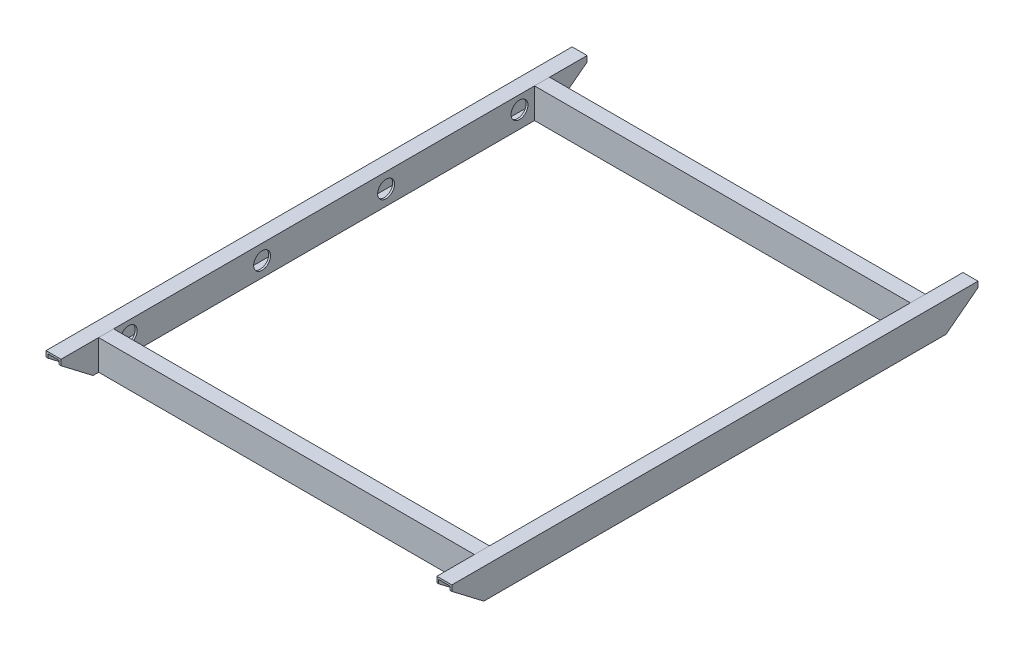
from build123d import *

# Parameters (mm, degrees)
SKETCH12_W                               = 50.8
SKETCH12_H                               = 25.4
SKETCH12_W_2                             = 44.45
SKETCH12_H_2                             = 19.05
RECTANGULAR_TUBE_2_X_1_X_0_125_1_DEPTH   = 889
SKETCH12_ON_SEGMENT_2_W                  = 50.8
SKETCH12_ON_SEGMENT_2_H                  = 25.4
SKETCH12_ON_SEGMENT_2_W_2                = 44.45
SKETCH12_ON_SEGMENT_2_H_2                = 19.05
RECTANGULAR_TUBE_2_X_1_X_0_125_1_2_DEPTH = 889
SKETCH13_W                               = 50.8
SKETCH13_H                               = 25.4
SKETCH13_W_2                             = 44.45
SKETCH13_H_2                             = 19.05
RECTANGULAR_TUBE_2_X_1_X_0_125_2_DEPTH   = 660.4
SKETCH13_ON_SEGMENT_2_W                  = 50.8
SKETCH13_ON_SEGMENT_2_H                  = 25.4
SKETCH13_ON_SEGMENT_2_W_2                = 44.45
SKETCH13_ON_SEGMENT_2_H_2                = 19.05
RECTANGULAR_TUBE_2_X_1_X_0_125_2_2_DEPTH = 660.4
CUT_EXTRUDE1_DEPTH                       = 818.647265023
SKETCH15_R                               = 14.2875
CUT_EXTRUDE2_DEPTH                       = 797.46316299


with BuildPart() as part:
    # Sketch12 → Rectangular tube 2 X 1 X 0.125(1) (new body)
    with BuildSketch(Plane(origin=(-330.2, 0, 444.5), x_dir=(0, 1, 0), z_dir=(0, 0, -1))):
        Rectangle(SKETCH12_W, SKETCH12_H)
        Rectangle(SKETCH12_W_2, SKETCH12_H_2, mode=Mode.SUBTRACT)
    extrude(amount=RECTANGULAR_TUBE_2_X_1_X_0_125_1_DEPTH)


with BuildPart() as body_2:
    # Sketch12 on segment 2 (carried to segment 2) → Rectangular tube 2 X 1 X 0.125_1 2 (new body)
    with BuildSketch(Plane(origin=(330.2, 0, 444.5), x_dir=(0, 1, 0), z_dir=(0, 0, -1))):
        Rectangle(SKETCH12_ON_SEGMENT_2_W, SKETCH12_ON_SEGMENT_2_H)
        Rectangle(SKETCH12_ON_SEGMENT_2_W_2, SKETCH12_ON_SEGMENT_2_H_2, mode=Mode.SUBTRACT)
    extrude(amount=RECTANGULAR_TUBE_2_X_1_X_0_125_1_2_DEPTH)


with BuildPart() as body_3:
    # Sketch13 → Rectangular tube 2 X 1 X 0.125(2) (new body)
    with BuildSketch(Plane(origin=(-330.2, 0, -368.3), x_dir=(0, 1, 0), z_dir=(1, 0, 0))):
        Rectangle(SKETCH13_W, SKETCH13_H)
        Rectangle(SKETCH13_W_2, SKETCH13_H_2, mode=Mode.SUBTRACT)
    extrude(amount=RECTANGULAR_TUBE_2_X_1_X_0_125_2_DEPTH)

    # Trim_Extend1 21
    split(bisect_by=Plane.YZ.offset(-317.5), keep=Keep.TOP)

    # Trim_Extend1 26
    split(bisect_by=Plane(origin=(317.5, 0, 0), x_dir=(0, -1, 0), z_dir=(-1, 0, 0)), keep=Keep.TOP)


with BuildPart() as body_4:
    # Sketch13 on segment 2 (carried to segment 2) → Rectangular tube 2 X 1 X 0.125_2 2 (new body)
    with BuildSketch(Plane(origin=(-330.2, 0, 368.3), x_dir=(0, 1, 0), z_dir=(1, 0, 0))):
        Rectangle(SKETCH13_ON_SEGMENT_2_W, SKETCH13_ON_SEGMENT_2_H)
        Rectangle(SKETCH13_ON_SEGMENT_2_W_2, SKETCH13_ON_SEGMENT_2_H_2, mode=Mode.SUBTRACT)
    extrude(amount=RECTANGULAR_TUBE_2_X_1_X_0_125_2_2_DEPTH)

    # Trim_Extend1 3
    split(bisect_by=Plane.YZ.offset(-317.5), keep=Keep.TOP)

    # Trim_Extend1 26
    split(bisect_by=Plane(origin=(317.5, 0, 0), x_dir=(0, -1, 0), z_dir=(-1, 0, 0)), keep=Keep.TOP)


with BuildPart() as cut_extrude1_tool:
    # Sketch14 → Cut-Extrude1 (new, through all)
    with BuildSketch(Plane.ZY.offset(342.9)):
        Polygon((-444.5, 15.875), (-390.525, -25.4), (-444.5, -25.4), align=None)
        Polygon((444.5, -25.4), (444.5, 15.875), (390.525, -25.4), align=None)
    extrude(amount=-CUT_EXTRUDE1_DEPTH)


with BuildPart() as part_1:
    add(part.part)

    # Cut-Extrude1: cut by cut_extrude1_tool
    add(cut_extrude1_tool.part, mode=Mode.SUBTRACT)

    # Sketch15 → Cut-Extrude2 (cut, through all)
    with BuildSketch(Plane(origin=(-317.5, 0, 0), x_dir=(0, 0, -1), z_dir=(1, 0, 0))):
        with Locations(Location((330.2, 3.175, 0), (0, 0, 90))):
            Circle(SKETCH15_R)
        with Locations(Location((104.775, 0, 0), (0, 0, 90))):
            Circle(SKETCH15_R)
        with Locations(Location((-330.2, 3.175, 0), (0, 0, 90))):
            Circle(SKETCH15_R)
        with Locations(Location((-104.775, 0, 0), (0, 0, 90))):
            Circle(SKETCH15_R)
    extrude(amount=-CUT_EXTRUDE2_DEPTH, mode=Mode.SUBTRACT)


with BuildPart() as body_2_1:
    add(body_2.part)

    # Cut-Extrude1: cut by cut_extrude1_tool
    add(cut_extrude1_tool.part, mode=Mode.SUBTRACT)


solid = Compound([body_3.part, body_4.part, part_1.part, body_2_1.part])
